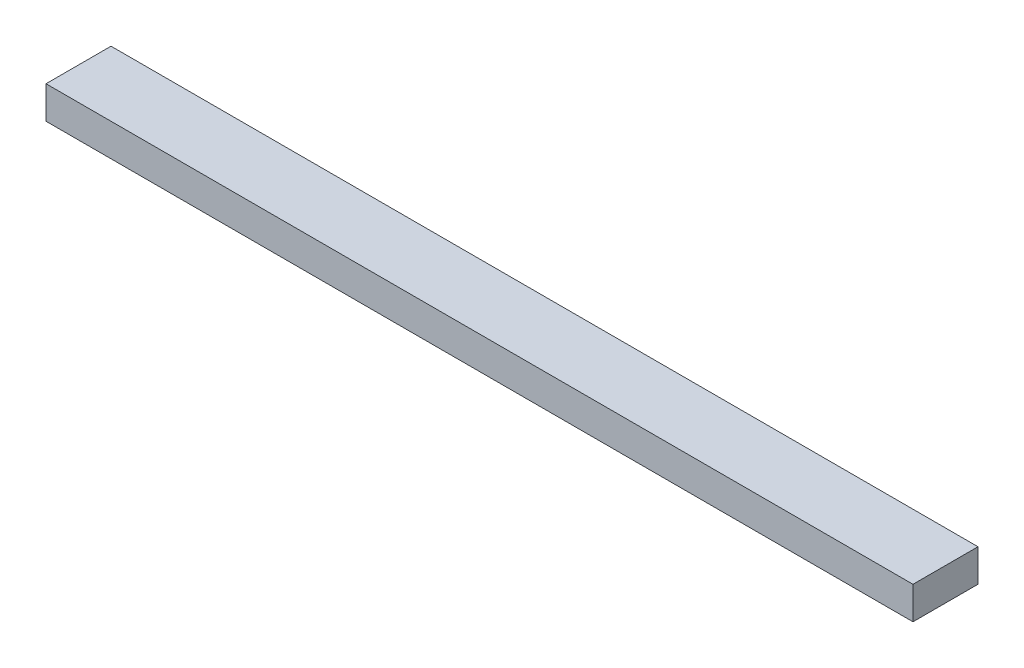
from build123d import *

# Parameters (mm, degrees)
SKETCH1_W           = 508
SKETCH1_H           = 38.1
BOSS_EXTRUDE1_DEPTH = 19.05


with BuildPart() as part:
    # Sketch1 → Boss-Extrude1 (new body)
    with BuildSketch(Plane(origin=(0, 0, 0), x_dir=(1, 0, 0), z_dir=(0, 1, 0))):
        with Locations((254, 19.05)):
            Rectangle(SKETCH1_W, SKETCH1_H)
    extrude(amount=BOSS_EXTRUDE1_DEPTH)


solid = part.part
